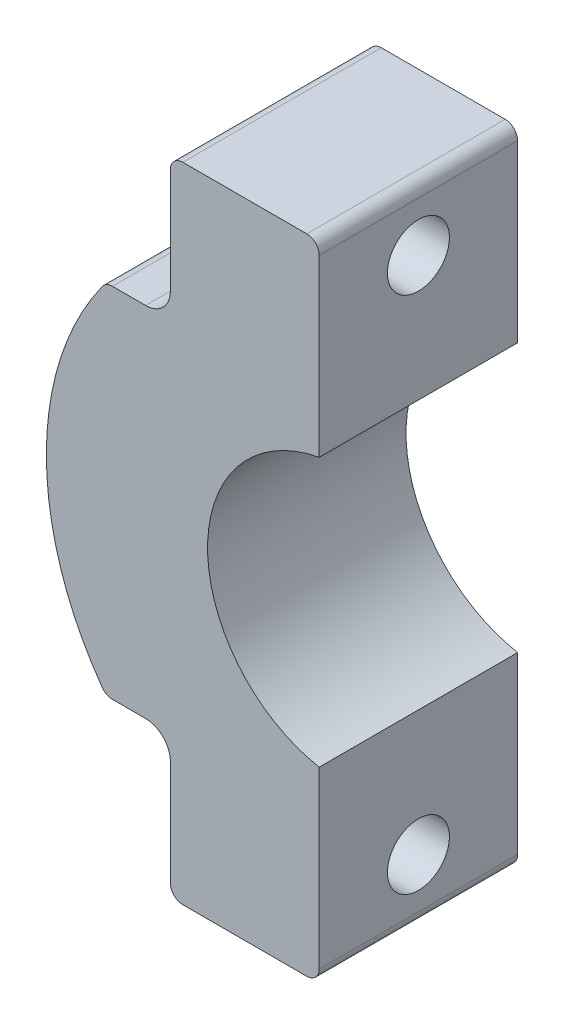
from build123d import *

# Parameters (mm, degrees)
ESQUISSE1_R             = 13
ESQUISSE1_R_2           = 5.5
BOSS_EXTRU_1_DEPTH      = 8
ESQUISSE2_W             = 32.31004566
ESQUISSE2_H             = 49.818141682
ENL_V_MAT_EXTRU_1_DEPTH = 8
ESQUISSE3_R             = 1.5
ENL_V_MAT_EXTRU_2_DEPTH = 8
ESQUISSE4_W             = 21.87123002
ESQUISSE4_H             = 13.833010023
ESQUISSE4_W_2           = 20.432073676
ESQUISSE4_H_2           = 10.309386407
ENL_V_MAT_EXTRU_3_DEPTH = 8
ENL_V_MAT_EXTRU_4_DEPTH = 8
CONG_4_R                = 0.5
ESQUISSE7_W             = 6
ESQUISSE7_H             = 5.75
BOSS_EXTRU_3_DEPTH      = 8
ESQUISSE11_R            = 1.25
ENL_V_MAT_EXTRU_5_DEPTH = 8
CONG_5_R                = 0.5
CONG_6_R                = 1
CONG_7_R                = 0.5


with BuildPart() as part:
    # Esquisse1 → Boss.-Extru.1 (new body)
    with BuildSketch(Plane.XY):
        Circle(ESQUISSE1_R)
        Circle(ESQUISSE1_R_2, mode=Mode.SUBTRACT)
    extrude(amount=BOSS_EXTRU_1_DEPTH)

    # Esquisse2 → Enlèv. mat.-Extru.1 (cut)
    with BuildSketch(Plane.XY.offset(8)):
        with Locations((15.15502283, -0.665904075)):
            Rectangle(ESQUISSE2_W, ESQUISSE2_H)
    extrude(amount=-ENL_V_MAT_EXTRU_1_DEPTH, mode=Mode.SUBTRACT)

    # Esquisse3 → Enlèv. mat.-Extru.2 (cut)
    with BuildSketch(Plane(origin=(-1, 0, 0), x_dir=(0, 0, -1), z_dir=(1, 0, 0))):
        with Locations((-4, 10.461481397)):
            Circle(ESQUISSE3_R)
        with Locations((-4, -10.461481397)):
            Circle(ESQUISSE3_R)
    extrude(amount=-ENL_V_MAT_EXTRU_2_DEPTH, mode=Mode.SUBTRACT)

    # Esquisse4 → Enlèv. mat.-Extru.3 (cut)
    with BuildSketch(Plane.XY.offset(8)):
        with Locations((-17.93561501, 14.127986408)):
            Rectangle(ESQUISSE4_W, ESQUISSE4_H)
        with Locations((-17.216036838, -12.366174601)):
            Rectangle(ESQUISSE4_W_2, ESQUISSE4_H_2)
    extrude(amount=-ENL_V_MAT_EXTRU_3_DEPTH, mode=Mode.SUBTRACT)

    # Esquisse6 → Enlèv. mat.-Extru.4 (cut)
    with BuildSketch(Plane.XY.offset(8)):
        with BuildLine():
            Line((-16.733633374, -12.244867556), (-8.177661786, -8.782132299))
            ThreePointArc((-8.177661786, -8.782132299), (-11.997254104, 0.256698201), (-7.794537354, 9.123880065))
            Line((-7.794537354, 9.123880065), (-13.177897042, 8.696922023))
            ThreePointArc((-13.177897042, 8.696922023), (-19.765548318, -0.95731283), (-16.733633374, -12.244867556))
        make_face()
    extrude(amount=-ENL_V_MAT_EXTRU_4_DEPTH, mode=Mode.SUBTRACT)

    # Congé4
    cong_4_edges = [part.edges().sort_by_distance(p)[0] for p in [
        (-9.591378215, 7.211481397, 4),
        (-9.591378215, -7.211481397, 4),
    ]]
    fillet(cong_4_edges, radius=CONG_4_R)

    # Esquisse7 → Boss.-Extru.3 (add)
    with BuildSketch(Plane(origin=(0, 0, 0), x_dir=(-1, 0, 0), z_dir=(0, 0, -1))):
        with Locations((4, 10.086481397)):
            Rectangle(ESQUISSE7_W, ESQUISSE7_H)
        with Locations((4, -10.086481397)):
            Rectangle(ESQUISSE7_W, ESQUISSE7_H)
    extrude(amount=-BOSS_EXTRU_3_DEPTH)

    # Esquisse11 → Enlèv. mat.-Extru.5 (cut)
    with BuildSketch(Plane(origin=(-1, 0, 0), x_dir=(0, 0, -1), z_dir=(1, 0, 0))):
        with Locations((-4, 10.461481397)):
            Circle(ESQUISSE11_R)
        with Locations((-4, -10.461481397)):
            Circle(ESQUISSE11_R)
    extrude(amount=-ENL_V_MAT_EXTRU_5_DEPTH, mode=Mode.SUBTRACT)

    # Congé5
    cong_5_edges = [part.edges().sort_by_distance(p)[0] for p in [
        (-7, 12.961481397, 4),
        (-7, -12.961481397, 4),
    ]]
    fillet(cong_5_edges, radius=CONG_5_R)

    # Congé6
    cong_6_edges = [part.edges().sort_by_distance(p)[0] for p in [
        (-7, 7.211481397, 4),
        (-7, -7.211481397, 4),
    ]]
    fillet(cong_6_edges, radius=CONG_6_R)

    # Congé7
    cong_7_edges = [part.edges().sort_by_distance(p)[0] for p in [
        (-1, 12.961481397, 4),
        (-1, -12.961481397, 4),
    ]]
    fillet(cong_7_edges, radius=CONG_7_R)


solid = part.part
